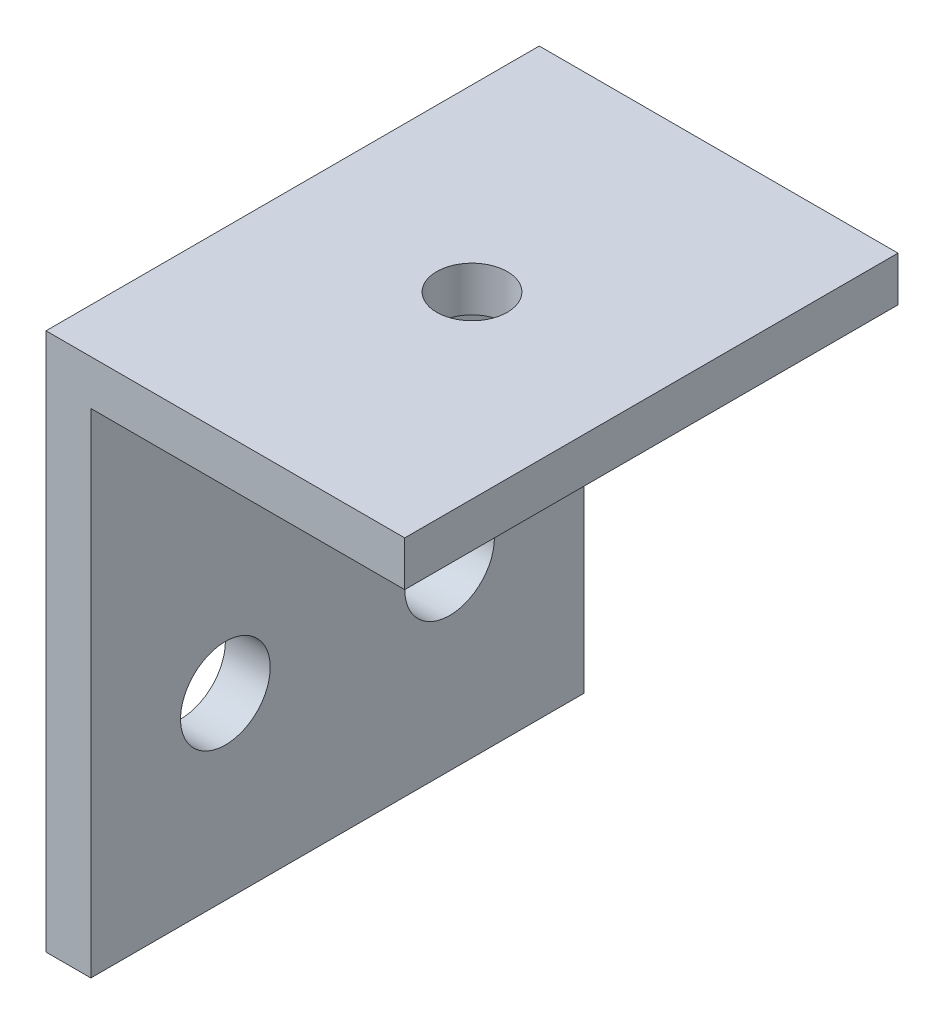
from build123d import *

# Parameters (mm, degrees)
BOSS_EXTRUDE1_DEPTH = 34.925
SKETCH2_R           = 3.175
CUT_EXTRUDE1_DEPTH  = 4.175
SKETCH3_R           = 2.5
CUT_EXTRUDE2_DEPTH  = 39.1


with BuildPart() as part:
    # Sketch1 → Boss-Extrude1 (new body)
    with BuildSketch(Plane.XY):
        Polygon((0, 0), (3.175, 0), (3.175, 34.925), (25.4, 34.925), (25.4, 38.1), (0, 38.1), align=None)
    extrude(amount=BOSS_EXTRUDE1_DEPTH)

    # Sketch2 → Cut-Extrude1 (cut, through all)
    with BuildSketch(Plane(origin=(3.175, 0, 0), x_dir=(0, 0, -1), z_dir=(1, 0, 0))):
        with Locations((-25.4, 12.7)):
            Circle(SKETCH2_R)
        with Locations((-9.525, 12.7)):
            Circle(SKETCH2_R)
    extrude(amount=-CUT_EXTRUDE1_DEPTH, mode=Mode.SUBTRACT)

    # Sketch3 → Cut-Extrude2 (cut, through all)
    with BuildSketch(Plane(origin=(0, 38.1, 0), x_dir=(1, 0, 0), z_dir=(0, 1, 0))):
        with Locations((12.7, -17.4625)):
            Circle(SKETCH3_R)
    extrude(amount=-CUT_EXTRUDE2_DEPTH, mode=Mode.SUBTRACT)


solid = part.part
